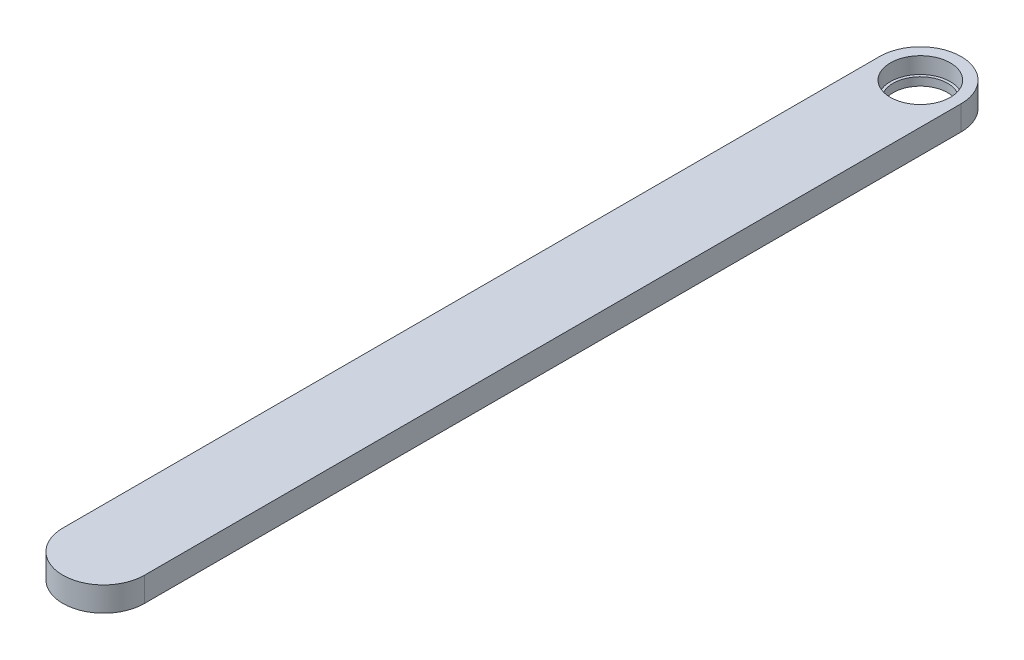
from build123d import *

# Parameters (mm, degrees)
EXTRUDE_1_DEPTH     = 9
SKETCH_3_R          = 11
CUT_EXTRUDE_1_DEPTH = 6
SKETCH_4_R          = 10
CUT_EXTRUDE_2_DEPTH = 4


with BuildPart() as part:
    # 스케치2 → 보스-돌출1 (new body)
    with BuildSketch(Plane(origin=(0, 0, 0), x_dir=(1, 0, 0), z_dir=(0, 1, 0))):
        with BuildLine():
            Line((-15, 0), (-15, -300))
            ThreePointArc((-15, -300), (0, -315), (15, -300))
            Line((15, -300), (15, 0))
            ThreePointArc((15, 0), (0, 15), (-15, 0))
        make_face()
    extrude(amount=EXTRUDE_1_DEPTH)

    # 스케치3 → 컷-돌출1 (cut)
    with BuildSketch(Plane(origin=(0, 9, 0), x_dir=(1, 0, 0), z_dir=(0, 1, 0))):
        Circle(SKETCH_3_R)
    extrude(amount=-CUT_EXTRUDE_1_DEPTH, mode=Mode.SUBTRACT)

    # 스케치4 → 컷-돌출2 (cut, through all)
    with BuildSketch(Plane(origin=(0, 3, 0), x_dir=(1, 0, 0), z_dir=(0, 1, 0))):
        Circle(SKETCH_4_R)
    extrude(amount=-CUT_EXTRUDE_2_DEPTH, mode=Mode.SUBTRACT)


solid = part.part
